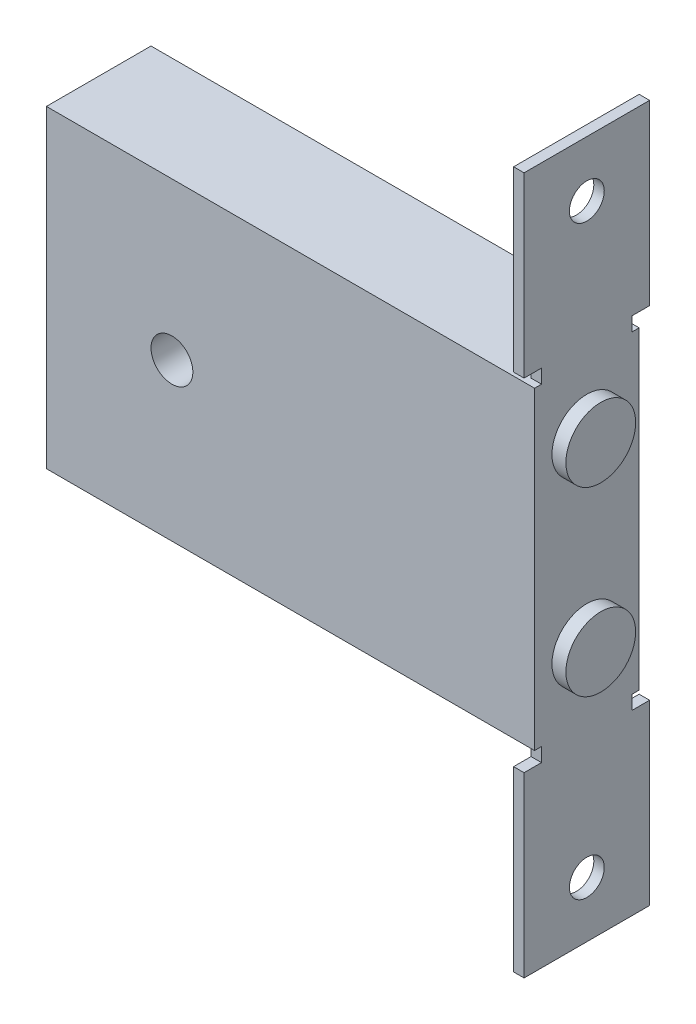
from build123d import *

# Parameters (mm, degrees)
SKETCH1_W           = 70
SKETCH1_H           = 45
SKETCH1_R           = 3
BOSS_EXTRUDE1_DEPTH = 15
SKETCH2_R           = 2.5
BOSS_EXTRUDE2_DEPTH = 1.5
SKETCH3_R           = 5
BOSS_EXTRUDE3_DEPTH = 2


with BuildPart() as part:
    # Sketch1 → Boss-Extrude1 (new body)
    with BuildSketch(Plane.XY):
        with Locations((35, 22.5)):
            Rectangle(SKETCH1_W, SKETCH1_H)
        with Locations((18, 22.5)):
            Circle(SKETCH1_R, mode=Mode.SUBTRACT)
    extrude(amount=BOSS_EXTRUDE1_DEPTH)

    # Sketch2 → Boss-Extrude2 (add)
    with BuildSketch(Plane(origin=(70, 0, 0), x_dir=(0, 0, -1), z_dir=(1, 0, 0))):
        Polygon((-1, 42.953382973), (-1, 47), (1.5, 47), (1.5, 72.5), (-16.5, 72.5), (-16.5, 47), (-14, 47), (-14, 42.953382973), align=None)
        with Locations((-7.5, 64.5)):
            Circle(SKETCH2_R, mode=Mode.SUBTRACT)
        Polygon((-14, 2.046617027), (-14, -2), (-16.5, -2), (-16.5, -27.5), (1.5, -27.5), (1.5, -2), (-1, -2), (-1, 2.046617027), align=None)
        with Locations((-7.5, -19.5)):
            Circle(SKETCH2_R, mode=Mode.SUBTRACT)
    extrude(amount=-BOSS_EXTRUDE2_DEPTH)

    # Sketch3 → Boss-Extrude3 (add)
    with BuildSketch(Plane(origin=(70, 0, 0), x_dir=(0, 0, -1), z_dir=(1, 0, 0))):
        with Locations((-7.5, 35.5)):
            Circle(SKETCH3_R)
        with Locations((-7.5, 9.5)):
            Circle(SKETCH3_R)
    extrude(amount=BOSS_EXTRUDE3_DEPTH)


solid = part.part
